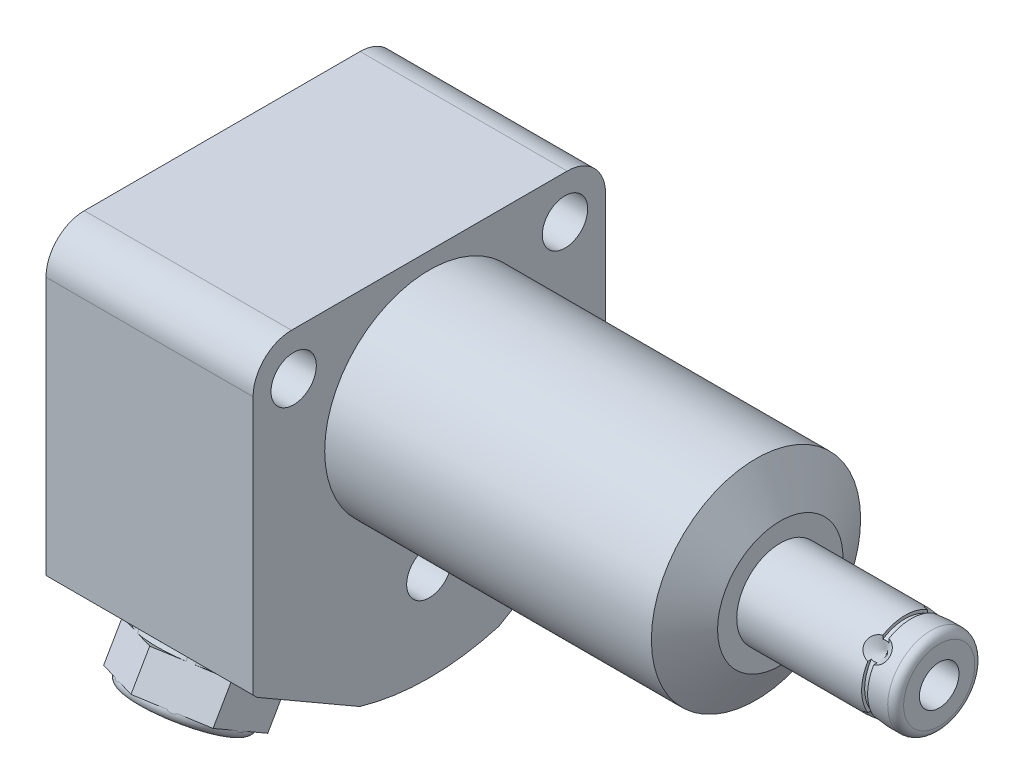
from build123d import *

# Parameters (mm, degrees)
EXTRUDE1_DEPTH           = 44.8056
EXTRUDE1_DEPTH_BACK      = 26.4414
CUT_EXTRUDE1_REACH       = 46.806
SKETCH2_R                = 13.3604
SKETCH11_W               = 0.762
SKETCH11_H               = 0.381
EXTRUDE2_DEPTH           = 6.78
SKETCH13_W               = 1
SKETCH13_H               = 1.25
SKETCH15_R               = 2.7432
EXTRUDE3_DEPTH           = 2.9972
CUT_EXTRUDE2_DEPTH       = 2.54
CHAMFER1_SIZE            = 0.381
CHAMFER1_OF_MIRROR2_SIZE = 0.381
SKETCH21_R               = 0.889
FILLET1_R                = 4.9022
SKETCH22_W               = 2.8955
SKETCH22_H               = 26.4414
HOLE1_AT_2_COUNT         = 2
HOLE1_AT_2_PITCH         = 34.639910603
HOLE1_AT_3_COUNT         = 2
HOLE1_AT_3_PITCH         = 34.639910603
CIRPATTERN1_COUNT        = 4


with BuildPart() as part:
    # Sketch1 → Extrude1 (new body, two sides)
    with BuildSketch(Plane(origin=(0, 0, 0), x_dir=(0, 0, -1), z_dir=(1, 0, 0))) as extrude1_sk:
        with BuildLine():
            Line((-22.5044, 15.494), (-22.5044, -22.396751564))
            ThreePointArc((-22.5044, -22.396751564), (-22.237765115, -22.661515896), (-21.968015496, -22.923106141))
            Line((-21.968015496, -22.923106141), (-8.867984504, -30.486412561))
            ThreePointArc((-8.867984504, -30.486412561), (0, -31.75), (8.867984504, -30.486412561))
            Line((8.867984504, -30.486412561), (21.968015496, -22.923106141))
            ThreePointArc((21.968015496, -22.923106141), (22.237765115, -22.661515896), (22.5044, -22.396751564))
            Line((22.5044, -22.396751564), (22.5044, 15.494))
            Line((22.5044, 15.494), (-22.5044, 15.494))
        make_face()
    extrude(amount=EXTRUDE1_DEPTH)
    extrude(extrude1_sk.sketch, amount=-EXTRUDE1_DEPTH_BACK)

    # Sketch2 → Cut-Extrude1 (cut, up to next)
    with BuildSketch(Plane(origin=(0, 0, 0), x_dir=(0, 0, -1), z_dir=(1, 0, 0)), mode=Mode.PRIVATE) as cut_extrude1_sk1:
        with BuildLine():
            Line((22.5044, 15.494), (-22.5044, 15.494))
            Line((-22.5044, 15.494), (-22.5044, -22.396751564))
            ThreePointArc((-22.5044, -22.396751564), (-22.237765115, -22.661515896), (-21.968015496, -22.923106141))
            Line((-21.968015496, -22.923106141), (-8.867984504, -30.486412561))
            ThreePointArc((-8.867984504, -30.486412561), (0, -31.75), (8.867984504, -30.486412561))
            Line((8.867984504, -30.486412561), (21.968015496, -22.923106141))
            ThreePointArc((21.968015496, -22.923106141), (22.237765115, -22.661515896), (22.5044, -22.396751564))
            Line((22.5044, -22.396751564), (22.5044, 15.494))
        make_face()
        Circle(SKETCH2_R, mode=Mode.SUBTRACT)
    cut_extrude1_tool1 = extrude(cut_extrude1_sk1.sketch, amount=CUT_EXTRUDE1_REACH, mode=Mode.PRIVATE) & part.part
    add(cut_extrude1_tool1.solids().sort_by_distance((0, -3.451376, -21.851883))[0], mode=Mode.SUBTRACT)

    # Sketch3 → Cut-Revolve1 (revolve, cut)
    with BuildSketch(Plane.XY, mode=Mode.PRIVATE) as cut_revolve1_sk:
        Polygon((41.711348967, 13.3604), (44.8056, 8.001), (44.8056, 13.3604), align=None)
    revolve(cut_revolve1_sk.sketch.rotate(Axis((23.304450239, 0, 0), (1, 0, 0)), 90), axis=Axis((23.304450239, 0, 0), (1, 0, 0)), mode=Mode.SUBTRACT)  # turned: the seam where the file's is

    # S2D0002 → Cut-Revolve2 (revolve, cut)
    with BuildSketch(Plane(origin=(-24.9936, -18.1864, 10.49), x_dir=(0, 1, 0), z_dir=(0, 0, 1)), mode=Mode.PRIVATE) as cut_revolve2_sk:
        Polygon((3.2512, 0), (5.7023, 0), (5.7023, 1.4478), (0, 1.4478), (0, -11.9888), (1.2446, -11.9888), (1.2446, -2.9972), (3.2512, -2.9972), align=None)
    cut_revolve2 = revolve(cut_revolve2_sk.sketch.rotate(Axis((-1.435104963, -18.1864, 10.49), (-1, 0, 0)), 90), axis=Axis((-1.435104963, -18.1864, 10.49), (-1, 0, 0)), mode=Mode.SUBTRACT)  # turned: the seam where the file's is

    # Sketch6 → Cut-Revolve4 (revolve, cut)
    with BuildSketch(Plane(origin=(-12.9286, 0, 0), x_dir=(0, 0, -1), z_dir=(1, 0, 0)), mode=Mode.PRIVATE) as cut_revolve4_sk:
        Polygon((-19.580423825, -24.008288899), (-22.435709581, -22.359788899), (-22.562709581, -22.579759351), (-15.418, -26.704759351), (-10.0078, -17.334018072), (-13.835285875, -15.124218072), (-18.788285875, -23.703065722), (-19.516923825, -23.898303672), align=None)
    cut_revolve4 = revolve(cut_revolve4_sk.sketch.rotate(Axis((-12.9286, -11.344731937, 6.549884038), (0, 0.866025404, -0.5)), 180), axis=Axis((-12.9286, -11.344731937, 6.549884038), (0, 0.866025404, -0.5)), mode=Mode.SUBTRACT)  # turned: the seam where the file's is

    # Mirror1: Cut-Revolve2, Cut-Revolve4 across plane
    add(cut_revolve2.mirror(Plane.XY), mode=Mode.SUBTRACT)
    add(cut_revolve4.mirror(Plane.XY), mode=Mode.SUBTRACT)

    # Sketch7 → Revolve1 (revolve)
    with BuildSketch(Plane.XY, mode=Mode.PRIVATE) as revolve1_sk:
        with BuildLine():
            Line((44.8056, 0), (44.8056, 5.55625))
            Line((44.8056, 5.55625), (64.0846, 5.55625))
            ThreePointArc((64.0846, 5.55625), (64.80302049, 5.25867049), (65.1006, 4.54025))
            Line((65.1006, 4.54025), (65.1006, 0))
            Line((65.1006, 0), (44.8056, 0))
        make_face()
    revolve(revolve1_sk.sketch.rotate(Axis((4.993122661, 0, 0), (1, 0, 0)), 90), axis=Axis((4.993122661, 0, 0), (1, 0, 0)))  # turned: the seam where the file's is

    # S2D0001 → Cut-Revolve8 (revolve, cut)
    with BuildSketch(Plane.XY, mode=Mode.PRIVATE) as cut_revolve8_sk:
        Polygon((65.1006, -2.5273), (54.9406, -2.5273), (53.422044958, 0), (65.1006, 0), align=None)
    revolve(cut_revolve8_sk.sketch.rotate(Axis((-2.5273, 0, 0), (-1, 0, 0)), 90), axis=Axis((-2.5273, 0, 0), (-1, 0, 0)), mode=Mode.SUBTRACT)  # turned: the seam where the file's is

    # Sketch9 → Cut-Revolve9 (revolve, cut)
    with BuildSketch(Plane(origin=(0, 0, 0), x_dir=(1, 0, 0), z_dir=(0, -0.707106781, 0.707106781)), mode=Mode.PRIVATE) as cut_revolve9_sk:
        Polygon((61.1382, -5.55625), (59.5507, -5.55625), (61.1382, -3.96875), align=None)
    cut_revolve9 = revolve(cut_revolve9_sk.sketch.rotate(Axis((61.1382, -4.421833392, -4.421833392), (0, 0.707106781, 0.707106781)), 270), axis=Axis((61.1382, -4.421833392, -4.421833392), (0, 0.707106781, 0.707106781)), mode=Mode.SUBTRACT)  # turned: the seam where the file's is

    # Sketch11 → Cut-Revolve5 (revolve, cut)
    with BuildSketch(Plane(origin=(0, 0, 0), x_dir=(1, 0, 0), z_dir=(0, 1, 0))):
        with Locations((61.1382, -5.36575)):
            Rectangle(SKETCH11_W, SKETCH11_H)
    revolve(axis=Axis((0, 0, 0), (1, 0, 0)), mode=Mode.SUBTRACT)

    # Sketch12 → Extrude2 (add)
    with BuildSketch(Plane(origin=(0, -26.484788899, 15.291), x_dir=(1, 0, 0), z_dir=(0, -0.866025404, 0.5))):
        Polygon((-12.9286, -8.065583261), (-5.9436, -4.03279163), (-5.9436, 4.03279163), (-12.9286, 8.065583261), (-19.9136, 4.03279163), (-19.9136, -4.03279163), align=None)
    extrude(amount=EXTRUDE2_DEPTH)

    # Sketch13 → Cut-Revolve6 (revolve, cut)
    with BuildSketch(Plane(origin=(-12.9286, -6.4643, -11.196496035), x_dir=(0, -0.866025404, 0.5), z_dir=(1, 0, 0))):
        with Locations((31.082, -5.3036)):
            Rectangle(SKETCH13_W, SKETCH13_H)
        with BuildLine():
            Line((36.362, -5.9286), (36.362, -4.6786))
            Line((36.362, -4.6786), (37.362, -4.6786))
            Line((37.362, -4.6786), (37.362, -6.9286))
            ThreePointArc((37.362, -6.9286), (37.069106781, -6.221493219), (36.362, -5.9286))
        make_face()
    revolve(axis=Axis((-12.9286, -26.051776197, 15.041), (0, -0.866025404, 0.5)), mode=Mode.SUBTRACT)

    # Sketch15 → Extrude3 (add)
    with BuildSketch(Plane.ZY.offset(21.9964)):
        with Locations(Location((10.49, -18.1864, 0), (0, 0, 180))):  # turned: the seam where the file's is
            Circle(SKETCH15_R)
    extrude3 = extrude(amount=EXTRUDE3_DEPTH)

    # Sketch16 → Cut-Extrude2 (cut)
    with BuildSketch(Plane.ZY.offset(24.9936)):
        Polygon((11.92714029, -18.1864), (11.208570145, -16.9418), (9.771429855, -16.9418), (9.05285971, -18.1864), (9.771429855, -19.431), (11.208570145, -19.431), align=None)
    cut_extrude2 = extrude(amount=-CUT_EXTRUDE2_DEPTH, mode=Mode.SUBTRACT)

    # Chamfer1
    chamfer1_edges = [part.edges().sort_by_distance(p)[0] for p in [
        (-24.9936, -18.1864, 13.2332),
    ]]
    chamfer(chamfer1_edges, length=CHAMFER1_SIZE)

    # Mirror2: Extrude3, Cut-Extrude2 across plane
    add(extrude3.mirror(Plane.XY))
    add(cut_extrude2.mirror(Plane.XY), mode=Mode.SUBTRACT)

    # Chamfer1 of Mirror2
    chamfer1_of_mirror2_edges = [part.edges().sort_by_distance(p)[0] for p in [
        (-24.9936, -18.1864, -13.2332),
    ]]
    chamfer(chamfer1_of_mirror2_edges, length=CHAMFER1_OF_MIRROR2_SIZE)

    # Fillet1
    fillet1_edges = [part.edges().sort_by_distance(p)[0] for p in [
        (-13.2207, 15.494, -22.5044),
        (-13.2207, 15.494, 22.5044),
    ]]
    fillet(fillet1_edges, radius=FILLET1_R)

    # Sketch22 → Hole1 (revolve, cut)
    with BuildSketch(Plane(origin=(0, -19.9898, 0), x_dir=(0, 0, -1), z_dir=(0, 1, 0))):
        with Locations((1.44775, 13.2207)):
            Rectangle(SKETCH22_W, SKETCH22_H)
    hole1 = revolve(axis=Axis((-110, -19.9898, 0), (1, 0, 0)), mode=Mode.SUBTRACT)

    # Hole1 at 2: Hole1 ×2
    with Locations(*[Vector(0, 0.865977985, 0.500082122) * (i * HOLE1_AT_2_PITCH) for i in range(1, HOLE1_AT_2_COUNT)]):
        add(hole1, mode=Mode.SUBTRACT)

    # Hole1 at 3: Hole1 ×2
    with Locations(*[Vector(0, 0.865977985, -0.500082122) * (i * HOLE1_AT_3_PITCH) for i in range(1, HOLE1_AT_3_COUNT)]):
        add(hole1, mode=Mode.SUBTRACT)

    # CirPattern1: Cut-Revolve9 ×4 about axis
    cirpattern1_axis = Axis((0, 0, 0), (1, 0, 0))
    for i in range(1, CIRPATTERN1_COUNT):
        add(cut_revolve9.rotate(cirpattern1_axis, i * 360 / CIRPATTERN1_COUNT), mode=Mode.SUBTRACT)


with BuildPart() as body_2:
    # Sketch21 → Revolve4 (revolve)
    with BuildSketch(Plane.XY.offset(10.49), mode=Mode.PRIVATE) as revolve4_sk:
        with Locations((-25.8572, -13.3731)):
            Circle(SKETCH21_R)
    revolve(revolve4_sk.sketch.rotate(Axis((-35.974373203, -18.1864, 10.49), (1, 0, 0)), 270), axis=Axis((-35.974373203, -18.1864, 10.49), (1, 0, 0)))  # turned: the seam where the file's is


with BuildPart() as body_3:
    # Mirror3: mirrored copy
    add(body_2.part.mirror(Plane.XY))


solid = Compound([part.part, body_2.part, body_3.part])
